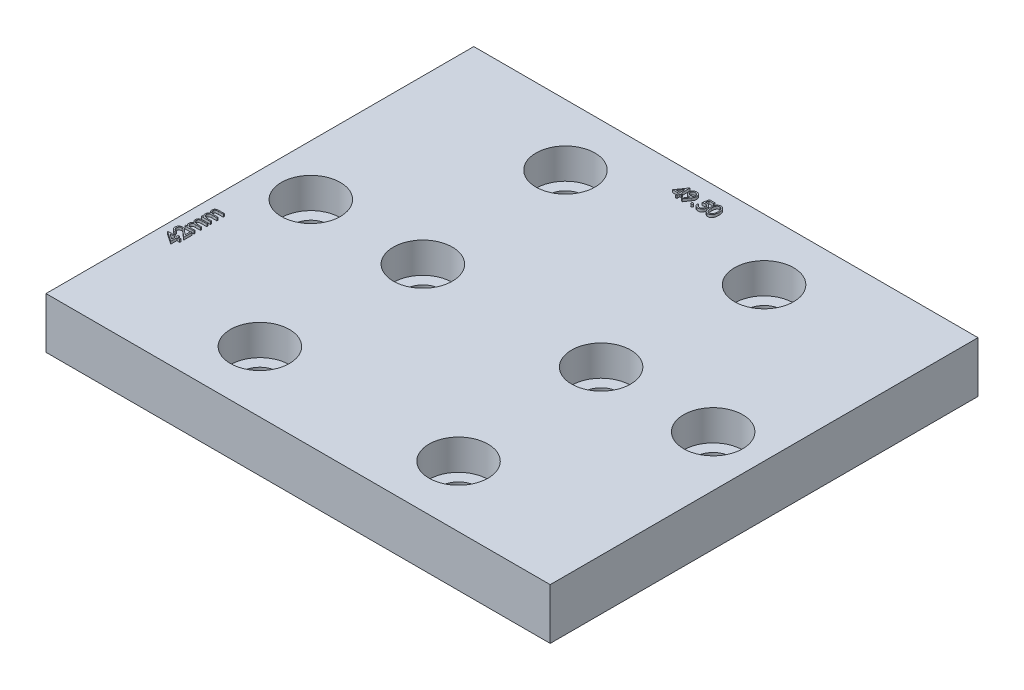
from build123d import *

# Parameters (mm, degrees)
SKETCH1_W               = 49.5
SKETCH1_H               = 42
BOSS_EXTRUDE1_DEPTH     = 5
SKETCH2_R               = 1.75
CUT_EXTRUDE1_DEPTH      = 33.841475302
BOSS_EXTRUDE2_DEPTH     = 0.25
BOSS_EXTRUDE3_DEPTH     = 0.25
SKETCH6_R               = 2.9
CUT_EXTRUDE2_DEPTH      = 33.841475441
CUT_EXTRUDE2_DEPTH_BACK = 3


with BuildPart() as part:
    # Sketch1 → Boss-Extrude1 (new body)
    with BuildSketch(Plane(origin=(0, 0, 0), x_dir=(1, 0, 0), z_dir=(0, 1, 0))):
        Rectangle(SKETCH1_W, SKETCH1_H)
    extrude(amount=BOSS_EXTRUDE1_DEPTH)

    # Sketch2 → Cut-Extrude1 (cut, through all)
    with BuildSketch(Plane(origin=(0, 5, 0), x_dir=(1, 0, 0), z_dir=(0, 1, 0))):
        with Locations(Location((-9.75, 15, 0), (0, 0, 270))):
            Circle(SKETCH2_R)
        with Locations(Location((9.75, 15, 0), (0, 0, 270))):
            Circle(SKETCH2_R)
        with Locations(Location((19.75, 0, 0), (0, 0, 270))):
            Circle(SKETCH2_R)
        with Locations(Location((-19.75, 0, 0), (0, 0, 270))):
            Circle(SKETCH2_R)
        with Locations(Location((-9.75, -15, 0), (0, 0, 270))):
            Circle(SKETCH2_R)
        with Locations(Location((9.75, -15, 0), (0, 0, 270))):
            Circle(SKETCH2_R)
        with Locations(Location((-8.75, 0, 0), (0, 0, 270))):
            Circle(SKETCH2_R)
        with Locations(Location((8.75, 0, 0), (0, 0, 270))):
            Circle(SKETCH2_R)
    extrude(amount=-CUT_EXTRUDE1_DEPTH, mode=Mode.SUBTRACT)

    # Sketch3 → Boss-Extrude2 (add)
    with BuildSketch(Plane(origin=(-31.590216695, 5, -10.723104051), x_dir=(0, 0, -1), z_dir=(0, 1, 0))):
        Polygon((-20.719932362, -7.772062893), (-20.697145903, -7.772062893), (-20.697145903, -8.637447508), (-20.552915134, -8.637447508), (-20.552915134, -8.765652636), (-20.697145903, -8.765652636), (-20.697145903, -9.054114175), (-20.80932539, -9.054114175), (-20.80932539, -8.765652636), (-21.402274108, -8.765652636), align=None)
        Polygon((-20.80932539, -8.637447508), (-20.80932539, -8.09507972), (-21.181671144, -8.637447508), align=None, mode=Mode.SUBTRACT)
        with BuildLine():
            Line((-20.280479237, -8.188729559), (-20.392658724, -8.188729559))
            add(Edge.make_bspline(
                [(-20.392658724, -8.188729559), (-20.391927598, -8.173847099), (-20.390491685, -8.144618344), (-20.383767296, -8.102002663), (-20.374145555, -8.061268807), (-20.360541464, -8.022743837), (-20.343646365, -7.986087121), (-20.323385641, -7.951444258), (-20.299387837, -7.918947405), (-20.272171146, -7.888897818), (-20.242610918, -7.861330828), (-20.21071594, -7.837525384), (-20.177199858, -7.81741193), (-20.142164359, -7.800597201), (-20.105214157, -7.787975828), (-20.066684565, -7.778610956), (-20.026406302, -7.772976547), (-19.998963437, -7.772370909), (-19.98500648, -7.772062893)],
                knots=[0, 0, 0, 0, 1.10065271, 2.161652631, 3.183658789, 4.190468796, 5.17591951, 6.163126047, 7.15150782, 8.156236427, 9.156009102, 10.134482811, 11.092018607, 12.041330605, 13.001268258, 13.972401359, 14.968799086, 16, 16, 16, 16], degree=3))
            add(Edge.make_bspline(
                [(-19.98500648, -7.772062893), (-19.971300025, -7.77238377), (-19.944367331, -7.773014282), (-19.905059468, -7.778428936), (-19.867639006, -7.786909504), (-19.832179089, -7.798807867), (-19.798962638, -7.814802305), (-19.767740122, -7.834015712), (-19.738139832, -7.85623708), (-19.711494552, -7.882399157), (-19.687027381, -7.91032858), (-19.665919433, -7.940145688), (-19.647843303, -7.970941862), (-19.632776275, -8.002951934), (-19.621684796, -8.036477301), (-19.613264008, -8.071029873), (-19.608504217, -8.106967306), (-19.607773709, -8.131291076), (-19.607402313, -8.143657444)],
                knots=[0, 0, 0, 0, 1.111607364, 2.184268762, 3.212621178, 4.221274766, 5.211760367, 6.196651075, 7.1921475, 8.207485113, 9.220403448, 10.201281604, 11.166441695, 12.114753415, 13.065576456, 14.026450734, 14.996634279, 16, 16, 16, 16], degree=3))
            add(Edge.make_bspline(
                [(-19.607402313, -8.143657444), (-19.608004687, -8.16106809), (-19.609198862, -8.19558385), (-19.61950447, -8.246371121), (-19.635426648, -8.295622928), (-19.654738444, -8.335258303), (-19.67424579, -8.367035765), (-19.691452859, -8.393434209), (-19.712042985, -8.4215865), (-19.735827776, -8.451776182), (-19.762448421, -8.4840956), (-19.792096517, -8.518558016), (-19.824998549, -8.554797411), (-19.848090757, -8.579549487), (-19.86005656, -8.592375393)],
                knots=[0, 0, 0, 0, 1.184203166, 2.347625244, 3.513805382, 4.700623107, 5.337941753, 6.051866363, 6.845199593, 7.711357327, 8.668078039, 9.695487809, 10.805859518, 12, 12, 12, 12], degree=3))
            Line((-19.86005656, -8.592375393), (-20.172806961, -8.925909047))
            Line((-20.172806961, -8.925909047), (-19.591376672, -8.925909047))
            Line((-19.591376672, -8.925909047), (-19.591376672, -9.054114175))
            Line((-19.591376672, -9.054114175), (-20.440735647, -9.054114175))
            Line((-20.440735647, -9.054114175), (-19.955960006, -8.53678645))
            add(Edge.make_bspline(
                [(-19.955960006, -8.53678645), (-19.944157189, -8.524465627), (-19.921486394, -8.500799846), (-19.889421188, -8.466248788), (-19.860621549, -8.434195381), (-19.834901052, -8.404700185), (-19.812817657, -8.377331768), (-19.793220431, -8.352976517), (-19.777518434, -8.330564213), (-19.760477222, -8.304585422), (-19.743972228, -8.272866738), (-19.729789244, -8.234104706), (-19.721141084, -8.194202116), (-19.720103642, -8.167237102), (-19.719581801, -8.15367347)],
                knots=[0, 0, 0, 0, 1.329631726, 2.553950428, 3.673215718, 4.687767853, 5.603093632, 6.413772471, 7.123043292, 7.734684054, 8.834405432, 9.900288307, 10.943827018, 12, 12, 12, 12], degree=3))
            add(Edge.make_bspline(
                [(-19.719581801, -8.15367347), (-19.719808851, -8.145144399), (-19.720256325, -8.128335238), (-19.724205503, -8.103690324), (-19.730173541, -8.079917176), (-19.738725418, -8.056942669), (-19.75001354, -8.034997794), (-19.763754033, -8.014055836), (-19.779607627, -7.993809777), (-19.797947366, -7.974826457), (-19.818094337, -7.957440312), (-19.839377998, -7.942038853), (-19.861895892, -7.929167742), (-19.885553079, -7.918616493), (-19.910283603, -7.910339571), (-19.936135298, -7.904604364), (-19.963036733, -7.901003477), (-19.981405838, -7.900516273), (-19.990765695, -7.900268021)],
                knots=[0, 0, 0, 0, 0.991446411, 1.95395049, 2.89581595, 3.838931463, 4.798493298, 5.75982156, 6.748411868, 7.785213223, 8.824556874, 9.840280684, 10.836137867, 11.835679398, 12.848801643, 13.863922112, 14.911575587, 16, 16, 16, 16], degree=3))
            add(Edge.make_bspline(
                [(-19.990765695, -7.900268021), (-20.000540992, -7.90052339), (-20.019738062, -7.901024891), (-20.047923431, -7.904532986), (-20.074811209, -7.910585072), (-20.100469031, -7.918862455), (-20.124940312, -7.929383366), (-20.148106042, -7.94248756), (-20.169914217, -7.958124522), (-20.190405832, -7.975853292), (-20.209285825, -7.995591721), (-20.225873995, -8.017595279), (-20.240368286, -8.041462213), (-20.25301444, -8.067128124), (-20.26328433, -8.094825903), (-20.271131883, -8.124457226), (-20.277341472, -8.155893434), (-20.279415943, -8.177602393), (-20.280479237, -8.188729559)],
                knots=[0, 0, 0, 0, 1.031018746, 2.02475058, 2.990194455, 3.934040569, 4.864654155, 5.795059489, 6.735614925, 7.690564532, 8.649604399, 9.611025574, 10.590972636, 11.591080095, 12.624614302, 13.701020113, 14.821632451, 16, 16, 16, 16], degree=3))
        make_face()
        with BuildLine():
            Line((-19.39906898, -8.140652636), (-19.286889493, -8.140652636))
            Line((-19.286889493, -8.140652636), (-19.286889493, -8.299406643))
            add(Edge.make_bspline(
                [(-19.286889493, -8.299406643), (-19.276788082, -8.285518213), (-19.257432811, -8.258906652), (-19.225695078, -8.223838693), (-19.193989323, -8.194078638), (-19.171155973, -8.178456184), (-19.160186769, -8.170951114)],
                knots=[0, 0, 0, 0, 1.134379233, 2.173579362, 3.122582517, 4, 4, 4, 4], degree=3))
            add(Edge.make_bspline(
                [(-19.160186769, -8.170951114), (-19.145235104, -8.163806341), (-19.115592996, -8.149641621), (-19.068657559, -8.135272493), (-19.020630891, -8.1264421), (-18.988199386, -8.125234467), (-18.971885487, -8.124626995)],
                knots=[0, 0, 0, 0, 1.014936303, 2.012140481, 3.000054389, 4, 4, 4, 4], degree=3))
            add(Edge.make_bspline(
                [(-18.971885487, -8.124626995), (-18.960852273, -8.125000313), (-18.939018138, -8.12573909), (-18.906666677, -8.130546245), (-18.875288602, -8.138855593), (-18.845069305, -8.150429637), (-18.816597634, -8.164446311), (-18.790494349, -8.180892635), (-18.767057132, -8.199355876), (-18.746297828, -8.220669781), (-18.727630319, -8.245432852), (-18.710459302, -8.274312941), (-18.694593155, -8.307958534), (-18.685799831, -8.332375156), (-18.681170342, -8.34522996)],
                knots=[0, 0, 0, 0, 1.009824226, 1.998387844, 2.986035974, 3.974953746, 4.955485308, 5.885931332, 6.793869504, 7.679848016, 8.601185859, 9.625726857, 10.749998409, 12, 12, 12, 12], degree=3))
            add(Edge.make_bspline(
                [(-18.681170342, -8.34522996), (-18.676273467, -8.33639981), (-18.666637104, -8.319023316), (-18.650456519, -8.294431079), (-18.633503734, -8.271428653), (-18.615634273, -8.249997788), (-18.596911206, -8.230244312), (-18.57724642, -8.212102919), (-18.556751855, -8.1954957), (-18.528254627, -8.176094571), (-18.491178696, -8.155487007), (-18.44443294, -8.137619705), (-18.395807879, -8.126578231), (-18.362801558, -8.125281705), (-18.346134285, -8.124626995)],
                knots=[0, 0, 0, 0, 0.86119277, 1.694706429, 2.50939023, 3.298075842, 4.073795165, 4.829715201, 5.57930267, 6.321991688, 7.768977793, 9.186738141, 10.579381044, 12, 12, 12, 12], degree=3))
            add(Edge.make_bspline(
                [(-18.346134285, -8.124626995), (-18.330819476, -8.125204574), (-18.30084691, -8.126334952), (-18.257212172, -8.135211193), (-18.21651867, -8.150453209), (-18.178848286, -8.171250937), (-18.144862638, -8.197386359), (-18.115321099, -8.228482373), (-18.090403112, -8.264319024), (-18.074125027, -8.298030448), (-18.063083861, -8.327793067), (-18.056276277, -8.353152457), (-18.0502621, -8.381063726), (-18.045268799, -8.411560248), (-18.041619316, -8.444749751), (-18.038915489, -8.480577921), (-18.037085462, -8.519072603), (-18.036956151, -8.545631711), (-18.036889493, -8.559322508)],
                knots=[0, 0, 0, 0, 1.209669288, 2.367440248, 3.500751976, 4.631527125, 5.755587489, 6.87532382, 8.007944318, 9.190864318, 9.82315674, 10.514484317, 11.263564316, 12.079023757, 12.955305781, 13.901327259, 14.918167583, 16, 16, 16, 16], degree=3))
            Line((-18.036889493, -8.559322508), (-18.036889493, -9.054114175))
            Line((-18.036889493, -9.054114175), (-18.14906898, -9.054114175))
            Line((-18.14906898, -9.054114175), (-18.14906898, -8.558821707))
            add(Edge.make_bspline(
                [(-18.14906898, -8.558821707), (-18.149096795, -8.547135788), (-18.149150252, -8.524677228), (-18.150112264, -8.49244421), (-18.151924876, -8.463062653), (-18.15404439, -8.436572622), (-18.156988607, -8.41291234), (-18.160790726, -8.392129334), (-18.164818469, -8.374060115), (-18.171509894, -8.354029384), (-18.18220557, -8.33193288), (-18.198497527, -8.308103032), (-18.219022565, -8.287359889), (-18.242722621, -8.269353347), (-18.269704208, -8.254712761), (-18.299441609, -8.244257043), (-18.331750199, -8.237784587), (-18.35411548, -8.237139581), (-18.365665535, -8.236806482)],
                knots=[0, 0, 0, 0, 1.253487763, 2.409012846, 3.458416907, 4.410876679, 5.259312806, 6.014470957, 6.676830364, 7.243083969, 8.276244668, 9.299465089, 10.325150304, 11.392391894, 12.482080715, 13.603491619, 14.762376348, 16, 16, 16, 16], degree=3))
            add(Edge.make_bspline(
                [(-18.365665535, -8.236806482), (-18.379833375, -8.237312253), (-18.407834415, -8.238311848), (-18.448707803, -8.248516802), (-18.487983166, -8.263902606), (-18.524488571, -8.286199912), (-18.558069925, -8.312917185), (-18.586962631, -8.344684898), (-18.610831269, -8.380624157), (-18.626993403, -8.413890837), (-18.637203868, -8.443772781), (-18.643945623, -8.469878985), (-18.649189692, -8.499550974), (-18.654107738, -8.532589363), (-18.657317641, -8.569221571), (-18.660234916, -8.609278143), (-18.66159951, -8.652879557), (-18.661790388, -8.683103374), (-18.661889493, -8.698795665)],
                knots=[0, 0, 0, 0, 1.090531906, 2.155305635, 3.229839962, 4.33261226, 5.44038871, 6.529323825, 7.629011124, 8.757537029, 9.370236727, 10.061839251, 10.834451254, 11.692844982, 12.636905849, 13.66920014, 14.789842145, 16, 16, 16, 16], degree=3))
            Line((-18.661889493, -8.698795665), (-18.661889493, -9.054114175))
            Line((-18.661889493, -9.054114175), (-18.77406898, -9.054114175))
            Line((-18.77406898, -9.054114175), (-18.77406898, -8.589620986))
            add(Edge.make_bspline(
                [(-18.77406898, -8.589620986), (-18.774097348, -8.576516229), (-18.774151926, -8.551303994), (-18.775107754, -8.51514911), (-18.776924404, -8.48226301), (-18.7790246, -8.452683916), (-18.782046092, -8.426465584), (-18.78547815, -8.403467456), (-18.789531225, -8.383747188), (-18.796241898, -8.362117408), (-18.806497066, -8.338288507), (-18.822992874, -8.312880999), (-18.843567009, -8.290642393), (-18.867699465, -8.271657126), (-18.894844352, -8.255963739), (-18.924838423, -8.244656685), (-18.957411606, -8.238076582), (-18.97986793, -8.237237833), (-18.991416737, -8.236806482)],
                knots=[0, 0, 0, 0, 1.320475261, 2.540461679, 3.643808994, 4.639130445, 5.527981419, 6.302341397, 6.981980563, 7.553956391, 8.582137848, 9.585246428, 10.591171744, 11.620968678, 12.668337649, 13.738356861, 14.836885341, 16, 16, 16, 16], degree=3))
            add(Edge.make_bspline(
                [(-18.991416737, -8.236806482), (-19.004993955, -8.237353075), (-19.032052869, -8.238442415), (-19.071803572, -8.248247513), (-19.110191317, -8.263606111), (-19.146603709, -8.28491319), (-19.180058762, -8.311305718), (-19.209347429, -8.342346752), (-19.233969759, -8.377649978), (-19.25030255, -8.410565877), (-19.26083772, -8.439699189), (-19.267836054, -8.464467385), (-19.273850206, -8.491967474), (-19.278319499, -8.522284299), (-19.282633933, -8.555220404), (-19.284716187, -8.590939865), (-19.286741744, -8.629412039), (-19.286839035, -8.655973662), (-19.286889493, -8.669749191)],
                knots=[0, 0, 0, 0, 1.098833095, 2.189935336, 3.297829714, 4.440610912, 5.596351641, 6.740013378, 7.886572111, 9.072425424, 9.705826452, 10.395263256, 11.156850408, 11.985370555, 12.878090359, 13.847760091, 14.883794034, 16, 16, 16, 16], degree=3))
            Line((-19.286889493, -8.669749191), (-19.286889493, -9.054114175))
            Line((-19.286889493, -9.054114175), (-19.39906898, -9.054114175))
            Line((-19.39906898, -9.054114175), (-19.39906898, -8.140652636))
        make_face()
        with BuildLine():
            Line((-17.780479237, -8.140652636), (-17.668299749, -8.140652636))
            Line((-17.668299749, -8.140652636), (-17.668299749, -8.299406643))
            add(Edge.make_bspline(
                [(-17.668299749, -8.299406643), (-17.658198339, -8.285518213), (-17.638843067, -8.258906652), (-17.607105334, -8.223838693), (-17.57539958, -8.194078638), (-17.552566229, -8.178456184), (-17.541597025, -8.170951114)],
                knots=[0, 0, 0, 0, 1.134379233, 2.173579362, 3.122582517, 4, 4, 4, 4], degree=3))
            add(Edge.make_bspline(
                [(-17.541597025, -8.170951114), (-17.52664536, -8.163806341), (-17.497003253, -8.149641621), (-17.450067815, -8.135272493), (-17.402041148, -8.1264421), (-17.369609643, -8.125234467), (-17.353295743, -8.124626995)],
                knots=[0, 0, 0, 0, 1.014936303, 2.012140481, 3.000054389, 4, 4, 4, 4], degree=3))
            add(Edge.make_bspline(
                [(-17.353295743, -8.124626995), (-17.34226253, -8.125000313), (-17.320428394, -8.12573909), (-17.288076934, -8.130546245), (-17.256698858, -8.138855593), (-17.226479562, -8.150429637), (-17.198007891, -8.164446311), (-17.171904606, -8.180892635), (-17.148467389, -8.199355876), (-17.127708085, -8.220669781), (-17.109040576, -8.245432852), (-17.091869559, -8.274312941), (-17.076003412, -8.307958534), (-17.067210087, -8.332375156), (-17.062580599, -8.34522996)],
                knots=[0, 0, 0, 0, 1.009824226, 1.998387844, 2.986035974, 3.974953746, 4.955485308, 5.885931332, 6.793869504, 7.679848016, 8.601185859, 9.625726857, 10.749998409, 12, 12, 12, 12], degree=3))
            add(Edge.make_bspline(
                [(-17.062580599, -8.34522996), (-17.057683723, -8.33639981), (-17.04804736, -8.319023316), (-17.031866775, -8.294431079), (-17.014913991, -8.271428653), (-16.997044529, -8.249997788), (-16.978321462, -8.230244312), (-16.958656676, -8.212102919), (-16.938162112, -8.1954957), (-16.909664883, -8.176094571), (-16.872588952, -8.155487007), (-16.825843197, -8.137619705), (-16.777218135, -8.126578231), (-16.744211815, -8.125281705), (-16.727544541, -8.124626995)],
                knots=[0, 0, 0, 0, 0.86119277, 1.694706429, 2.50939023, 3.298075842, 4.073795165, 4.829715201, 5.57930267, 6.321991688, 7.768977793, 9.186738141, 10.579381044, 12, 12, 12, 12], degree=3))
            add(Edge.make_bspline(
                [(-16.727544541, -8.124626995), (-16.712229733, -8.125204574), (-16.682257166, -8.126334952), (-16.638622429, -8.135211193), (-16.597928927, -8.150453209), (-16.560258542, -8.171250937), (-16.526272895, -8.197386359), (-16.496731356, -8.228482373), (-16.471813369, -8.264319024), (-16.455535283, -8.298030448), (-16.444494117, -8.327793067), (-16.437686534, -8.353152457), (-16.431672357, -8.381063726), (-16.426679055, -8.411560248), (-16.423029572, -8.444749751), (-16.420325745, -8.480577921), (-16.418495719, -8.519072603), (-16.418366407, -8.545631711), (-16.418299749, -8.559322508)],
                knots=[0, 0, 0, 0, 1.209669288, 2.367440248, 3.500751976, 4.631527125, 5.755587489, 6.87532382, 8.007944318, 9.190864318, 9.82315674, 10.514484317, 11.263564316, 12.079023757, 12.955305781, 13.901327259, 14.918167583, 16, 16, 16, 16], degree=3))
            Line((-16.418299749, -8.559322508), (-16.418299749, -9.054114175))
            Line((-16.418299749, -9.054114175), (-16.530479237, -9.054114175))
            Line((-16.530479237, -9.054114175), (-16.530479237, -8.558821707))
            add(Edge.make_bspline(
                [(-16.530479237, -8.558821707), (-16.530507052, -8.547135788), (-16.530560509, -8.524677228), (-16.53152252, -8.49244421), (-16.533335132, -8.463062653), (-16.535454646, -8.436572622), (-16.538398864, -8.41291234), (-16.542200982, -8.392129334), (-16.546228725, -8.374060115), (-16.55292015, -8.354029384), (-16.563615826, -8.33193288), (-16.579907783, -8.308103032), (-16.600432821, -8.287359889), (-16.624132877, -8.269353347), (-16.651114464, -8.254712761), (-16.680851865, -8.244257043), (-16.713160455, -8.237784587), (-16.735525737, -8.237139581), (-16.747075791, -8.236806482)],
                knots=[0, 0, 0, 0, 1.253487763, 2.409012846, 3.458416907, 4.410876679, 5.259312806, 6.014470957, 6.676830364, 7.243083969, 8.276244668, 9.299465089, 10.325150304, 11.392391894, 12.482080715, 13.603491619, 14.762376348, 16, 16, 16, 16], degree=3))
            add(Edge.make_bspline(
                [(-16.747075791, -8.236806482), (-16.761243632, -8.237312253), (-16.789244672, -8.238311848), (-16.830118059, -8.248516802), (-16.869393423, -8.263902606), (-16.905898827, -8.286199912), (-16.939480181, -8.312917185), (-16.968372887, -8.344684898), (-16.992241525, -8.380624157), (-17.008403659, -8.413890837), (-17.018614124, -8.443772781), (-17.02535588, -8.469878985), (-17.030599948, -8.499550974), (-17.035517994, -8.532589363), (-17.038727897, -8.569221571), (-17.041645173, -8.609278143), (-17.043009767, -8.652879557), (-17.043200645, -8.683103374), (-17.043299749, -8.698795665)],
                knots=[0, 0, 0, 0, 1.090531906, 2.155305635, 3.229839962, 4.33261226, 5.44038871, 6.529323825, 7.629011124, 8.757537029, 9.370236727, 10.061839251, 10.834451254, 11.692844982, 12.636905849, 13.66920014, 14.789842145, 16, 16, 16, 16], degree=3))
            Line((-17.043299749, -8.698795665), (-17.043299749, -9.054114175))
            Line((-17.043299749, -9.054114175), (-17.155479237, -9.054114175))
            Line((-17.155479237, -9.054114175), (-17.155479237, -8.589620986))
            add(Edge.make_bspline(
                [(-17.155479237, -8.589620986), (-17.155507605, -8.576516229), (-17.155562182, -8.551303994), (-17.15651801, -8.51514911), (-17.158334661, -8.48226301), (-17.160434856, -8.452683916), (-17.163456349, -8.426465584), (-17.166888407, -8.403467456), (-17.170941482, -8.383747188), (-17.177652155, -8.362117408), (-17.187907322, -8.338288507), (-17.20440313, -8.312880999), (-17.224977266, -8.290642393), (-17.249109721, -8.271657126), (-17.276254608, -8.255963739), (-17.30624868, -8.244656685), (-17.338821863, -8.238076582), (-17.361278186, -8.237237833), (-17.372826993, -8.236806482)],
                knots=[0, 0, 0, 0, 1.320475261, 2.540461679, 3.643808994, 4.639130445, 5.527981419, 6.302341397, 6.981980563, 7.553956391, 8.582137848, 9.585246428, 10.591171744, 11.620968678, 12.668337649, 13.738356861, 14.836885341, 16, 16, 16, 16], degree=3))
            add(Edge.make_bspline(
                [(-17.372826993, -8.236806482), (-17.386404211, -8.237353075), (-17.413463125, -8.238442415), (-17.453213829, -8.248247513), (-17.491601573, -8.263606111), (-17.528013965, -8.28491319), (-17.561469018, -8.311305718), (-17.590757685, -8.342346752), (-17.615380016, -8.377649978), (-17.631712807, -8.410565877), (-17.642247976, -8.439699189), (-17.64924631, -8.464467385), (-17.655260462, -8.491967474), (-17.659729756, -8.522284299), (-17.66404419, -8.555220404), (-17.666126443, -8.590939865), (-17.668152001, -8.629412039), (-17.668249292, -8.655973662), (-17.668299749, -8.669749191)],
                knots=[0, 0, 0, 0, 1.098833095, 2.189935336, 3.297829714, 4.440610912, 5.596351641, 6.740013378, 7.886572111, 9.072425424, 9.705826452, 10.395263256, 11.156850408, 11.985370555, 12.878090359, 13.847760091, 14.883794034, 16, 16, 16, 16], degree=3))
            Line((-17.668299749, -8.669749191), (-17.668299749, -9.054114175))
            Line((-17.668299749, -9.054114175), (-17.780479237, -9.054114175))
            Line((-17.780479237, -9.054114175), (-17.780479237, -8.140652636))
        make_face()
    extrude(amount=BOSS_EXTRUDE2_DEPTH)

    # Sketch5 → Boss-Extrude3 (add)
    with BuildSketch(Plane(origin=(-2.612932279, 5, -18.047462483), x_dir=(1, 0, 0), z_dir=(0, 1, 0))):
        Polygon((0.73041867, 1.282051282), (0.753205128, 1.282051282), (0.753205128, 0.416666667), (0.897435897, 0.416666667), (0.897435897, 0.288461538), (0.753205128, 0.288461538), (0.753205128, 0), (0.641025641, 0), (0.641025641, 0.288461538), (0.048076923, 0.288461538), align=None)
        Polygon((0.641025641, 0.416666667), (0.641025641, 0.959034455), (0.268679888, 0.416666667), align=None, mode=Mode.SUBTRACT)
        with BuildLine():
            Line((1.282051282, -0.032051282), (1.192407853, 0.030298478))
            Line((1.192407853, 0.030298478), (1.539963942, 0.538361378))
            add(Edge.make_bspline(
                [(1.539963942, 0.538361378), (1.51778868, 0.53564957), (1.474124351, 0.530309868), (1.430146815, 0.52932892), (1.408503606, 0.528846154)],
                knots=[0, 0, 0, 0, 1.015715272, 2, 2, 2, 2], degree=3))
            add(Edge.make_bspline(
                [(1.408503606, 0.528846154), (1.395381446, 0.529182253), (1.369623793, 0.529841985), (1.331755346, 0.535071202), (1.295367646, 0.543124819), (1.260557162, 0.555142232), (1.227193053, 0.570077306), (1.195348155, 0.588597669), (1.165065337, 0.61038563), (1.136669833, 0.635325984), (1.110844212, 0.662711003), (1.087835892, 0.691695161), (1.068714059, 0.72261515), (1.052829564, 0.754840229), (1.040782974, 0.788833568), (1.032010639, 0.824208354), (1.026609798, 0.861212512), (1.025967264, 0.886400059), (1.025641026, 0.899188702)],
                knots=[0, 0, 0, 0, 1.060718605, 2.082097864, 3.085795603, 4.069760067, 5.054557537, 6.03741023, 7.043284206, 8.066802108, 9.088538119, 10.083643548, 11.053783639, 12.022749082, 12.983451788, 13.964007469, 14.966251758, 16, 16, 16, 16], degree=3))
            add(Edge.make_bspline(
                [(1.025641026, 0.899188702), (1.026260467, 0.916677506), (1.027476304, 0.951004482), (1.037261488, 1.0011594), (1.053354467, 1.048583165), (1.075793173, 1.093151092), (1.104055573, 1.13422207), (1.138022927, 1.171225144), (1.177488628, 1.203634021), (1.221553635, 1.23149262), (1.269179714, 1.253897976), (1.319061378, 1.270412012), (1.37081642, 1.280125851), (1.405876303, 1.281406515), (1.423527644, 1.282051282)],
                knots=[0, 0, 0, 0, 1.022988612, 2.007919123, 2.978103895, 3.94594894, 4.918897164, 5.887013414, 6.875921846, 7.89917871, 8.930658928, 9.948724884, 10.967259574, 12, 12, 12, 12], degree=3))
            add(Edge.make_bspline(
                [(1.423527644, 1.282051282), (1.440844937, 1.281397652), (1.475062275, 1.280106142), (1.525379777, 1.270647581), (1.573572998, 1.254705913), (1.619374779, 1.232675711), (1.661781712, 1.205061101), (1.69991593, 1.172155914), (1.732907194, 1.133939655), (1.760701437, 1.091336622), (1.783012166, 1.045562701), (1.79910941, 0.997782728), (1.809018566, 0.948340328), (1.810267255, 0.914842301), (1.810897436, 0.897936699)],
                knots=[0, 0, 0, 0, 1.026385292, 2.028040595, 3.023318987, 4.028184125, 5.03290303, 6.015178782, 7.004435299, 8.016004309, 9.023023918, 10.015172535, 10.998308025, 12, 12, 12, 12], degree=3))
            add(Edge.make_bspline(
                [(1.810897436, 0.897936699), (1.810476576, 0.884813925), (1.809622966, 0.85819766), (1.803645713, 0.817758252), (1.793495647, 0.77652567), (1.781977183, 0.7416251), (1.770858552, 0.712800654), (1.760393862, 0.690032232), (1.748782379, 0.666067496), (1.735239962, 0.641157732), (1.720681999, 0.614985398), (1.704232258, 0.587813), (1.686265982, 0.559604073), (1.673469653, 0.540587256), (1.666917067, 0.530849359)],
                knots=[0, 0, 0, 0, 1.179839688, 2.393009684, 3.667231171, 4.993948276, 5.694988576, 6.444077775, 7.246288328, 8.089075292, 8.993003841, 9.939041771, 10.944649915, 12, 12, 12, 12], degree=3))
            Line((1.666917067, 0.530849359), (1.282051282, -0.032051282))
        make_face()
        with BuildLine():
            add(Edge.make_bspline(
                [(1.429286859, 0.657051282), (1.439227578, 0.657322848), (1.458578779, 0.657851494), (1.486927815, 0.66106908), (1.513686459, 0.666774075), (1.538926191, 0.674959687), (1.562900084, 0.684837068), (1.585227344, 0.697412778), (1.605926657, 0.712418719), (1.625136631, 0.729279439), (1.642195202, 0.74801179), (1.657389142, 0.767617899), (1.67030363, 0.788183831), (1.6805048, 0.809967139), (1.688892149, 0.832437571), (1.694684296, 0.855956984), (1.697892986, 0.880402841), (1.698439978, 0.897009505), (1.698717949, 0.905448718)],
                knots=[0, 0, 0, 0, 1.163407946, 2.26475976, 3.333800367, 4.359385343, 5.366239384, 6.363380779, 7.350133999, 8.353570782, 9.349036268, 10.310270964, 11.253520213, 12.184142, 13.120487599, 14.056272588, 15.012232024, 16, 16, 16, 16], degree=3))
            add(Edge.make_bspline(
                [(1.698717949, 0.905448718), (1.698478781, 0.913891456), (1.698007472, 0.930528906), (1.694226294, 0.955010955), (1.687574428, 0.978472834), (1.678649255, 1.001042988), (1.666892027, 1.022535978), (1.65278364, 1.043221646), (1.63602205, 1.062968835), (1.61673542, 1.081313115), (1.595937365, 1.098223079), (1.573772901, 1.113146677), (1.550424716, 1.125654247), (1.526035256, 1.135975308), (1.500553702, 1.144029514), (1.473995135, 1.14982143), (1.446225348, 1.153025628), (1.427374888, 1.153569161), (1.417768429, 1.153846154)],
                knots=[0, 0, 0, 0, 0.972161553, 1.915763587, 2.844109794, 3.775983486, 4.705125789, 5.659731448, 6.655561913, 7.682237399, 8.721216875, 9.739758359, 10.754845918, 11.767244016, 12.7857855, 13.828538656, 14.893392813, 16, 16, 16, 16], degree=3))
            add(Edge.make_bspline(
                [(1.417768429, 1.153846154), (1.408245518, 1.153568714), (1.389561643, 1.153024379), (1.362038729, 1.14982752), (1.33565974, 1.143990562), (1.310252019, 1.135979039), (1.285863283, 1.125653477), (1.2625162, 1.113146022), (1.240346551, 1.098226514), (1.219568436, 1.081299809), (1.20024775, 1.063054222), (1.183774347, 1.04313514), (1.169633671, 1.022546738), (1.157892598, 1.001040128), (1.148963128, 0.978473598), (1.142312413, 0.955010749), (1.138530925, 0.930528959), (1.138059659, 0.913891474), (1.137820513, 0.905448718)],
                knots=[0, 0, 0, 0, 1.099389452, 2.15699305, 3.192601482, 4.213358962, 5.227959689, 6.245255729, 7.266013209, 8.307253147, 9.336162325, 10.327954924, 11.284637477, 12.215801273, 13.149702402, 14.080068371, 15.025723358, 16, 16, 16, 16], degree=3))
            add(Edge.make_bspline(
                [(1.137820513, 0.905448718), (1.138036915, 0.897002933), (1.1384637, 0.880346298), (1.142580767, 0.855872587), (1.149465867, 0.832412517), (1.158687078, 0.809737979), (1.170830503, 0.788069458), (1.185731878, 0.767509686), (1.203198144, 0.747825597), (1.222995818, 0.729323021), (1.244663019, 0.712340101), (1.267804714, 0.697507822), (1.292022513, 0.684981949), (1.317401666, 0.674931455), (1.343754095, 0.666855861), (1.371316642, 0.661079595), (1.399998155, 0.657882356), (1.419430292, 0.657330965), (1.429286859, 0.657051282)],
                knots=[0, 0, 0, 0, 0.952633368, 1.87876736, 2.791047057, 3.707742249, 4.635551637, 5.587206343, 6.568248508, 7.601284464, 8.641511608, 9.671105535, 10.699146789, 11.713763218, 12.747829548, 13.806491675, 14.887386225, 16, 16, 16, 16], degree=3))
        make_face(mode=Mode.SUBTRACT)
        with BuildLine():
            add(Edge.make_bspline(
                [(2.171474359, 0.192307692), (2.178435149, 0.191894061), (2.192080964, 0.191083186), (2.211809224, 0.185520088), (2.22966446, 0.175641995), (2.245568833, 0.162476717), (2.258678289, 0.146513981), (2.268908415, 0.128801156), (2.274423052, 0.10890773), (2.275228021, 0.095182846), (2.275641026, 0.088141026)],
                knots=[0, 0, 0, 0, 1.020151414, 1.999887582, 2.974338812, 3.990962822, 5.007586832, 5.987933904, 6.967670073, 8, 8, 8, 8], degree=3))
            add(Edge.make_bspline(
                [(2.275641026, 0.088141026), (2.275214025, 0.081268408), (2.274371987, 0.067715707), (2.268921056, 0.047972327), (2.258600323, 0.030248433), (2.245659255, 0.014069098), (2.229660528, 0.000875929), (2.211767012, -0.008918122), (2.192127277, -0.014879544), (2.178442875, -0.015638935), (2.171474359, -0.016025641)],
                knots=[0, 0, 0, 0, 1.009421747, 1.99056486, 2.972319754, 3.999869655, 5.017953583, 5.993804169, 6.978383603, 8, 8, 8, 8], degree=3))
            add(Edge.make_bspline(
                [(2.171474359, -0.016025641), (2.164500821, -0.015652928), (2.150886649, -0.014925294), (2.131320222, -0.00879572), (2.113317734, 0.000784087), (2.097322122, 0.014093698), (2.084272668, 0.030165177), (2.07440646, 0.04809439), (2.068481407, 0.06765919), (2.067702167, 0.081257276), (2.067307692, 0.088141026)],
                knots=[0, 0, 0, 0, 1.022052826, 1.995314843, 2.982371812, 4.00089066, 5.028879526, 6.005146991, 6.990147033, 8, 8, 8, 8], degree=3))
            add(Edge.make_bspline(
                [(2.067307692, 0.088141026), (2.067687013, 0.095194376), (2.068427591, 0.108965176), (2.074418899, 0.128679142), (2.084196117, 0.146596442), (2.09741233, 0.162452364), (2.113313864, 0.175733543), (2.131276794, 0.185399541), (2.150933773, 0.191128259), (2.164508751, 0.19190773), (2.171474359, 0.192307692)],
                knots=[0, 0, 0, 0, 1.032775665, 2.016367738, 2.991239715, 4.008302682, 5.025365648, 6.011011707, 6.979408107, 8, 8, 8, 8], degree=3))
        make_face()
        with BuildLine():
            Line((3.221153846, 1.25), (3.221153846, 1.121794872))
            Line((3.221153846, 1.121794872), (2.796223958, 1.121794872))
            Line((2.796223958, 1.121794872), (2.728615785, 0.79301883))
            add(Edge.make_bspline(
                [(2.728615785, 0.79301883), (2.741850026, 0.796672499), (2.767489275, 0.803750903), (2.805332082, 0.811610107), (2.841257869, 0.816347766), (2.864570501, 0.816994662), (2.875851362, 0.817307692)],
                knots=[0, 0, 0, 0, 1.100273476, 2.13160584, 3.095893838, 4, 4, 4, 4], degree=3))
            add(Edge.make_bspline(
                [(2.875851362, 0.817307692), (2.889809841, 0.817005572), (2.917255697, 0.816411529), (2.957412464, 0.810707297), (2.99574564, 0.801728756), (3.032175058, 0.789185713), (3.066768111, 0.773146522), (3.099206526, 0.753110829), (3.12997721, 0.729706068), (3.158528136, 0.702797135), (3.184429675, 0.673182272), (3.207203242, 0.641340176), (3.226547025, 0.607580296), (3.242104437, 0.571580079), (3.254527414, 0.533737524), (3.262795983, 0.493654459), (3.268301951, 0.451708702), (3.268917089, 0.423028498), (3.269230769, 0.408403446)],
                knots=[0, 0, 0, 0, 1.052922333, 2.070308379, 3.05430497, 4.020497103, 4.973039431, 5.925935799, 6.892292201, 7.88610001, 8.88166317, 9.857072816, 10.836096531, 11.812156883, 12.81219415, 13.836441305, 14.89672472, 16, 16, 16, 16], degree=3))
            add(Edge.make_bspline(
                [(3.269230769, 0.408403446), (3.268993242, 0.398216938), (3.268521399, 0.377981586), (3.266121903, 0.347930085), (3.261502004, 0.318514788), (3.255299246, 0.289731791), (3.247248382, 0.261635586), (3.237502292, 0.234145755), (3.225575139, 0.207433395), (3.212492505, 0.181245754), (3.19776162, 0.156174859), (3.181412153, 0.132728792), (3.164138763, 0.110555835), (3.145552554, 0.089893787), (3.12548077, 0.070878424), (3.104166496, 0.053396894), (3.081779811, 0.037153562), (3.057974367, 0.022807778), (3.033280623, 0.009606722), (3.007341974, -0.001223112), (2.980748867, -0.010905444), (2.953118554, -0.018623132), (2.924513621, -0.024670473), (2.894886916, -0.02877783), (2.864393819, -0.031769415), (2.843724172, -0.031956686), (2.833283253, -0.032051282)],
                knots=[0, 0, 0, 0, 1.056347294, 2.098418968, 3.122841568, 4.141288669, 5.149314143, 6.15115421, 7.162517403, 8.180376062, 9.185164535, 10.17417709, 11.141909838, 12.097768115, 13.052685741, 14.0056014, 14.954263652, 15.917497458, 16.885230207, 17.854509472, 18.828990115, 19.81800267, 20.826176721, 21.857883937, 22.917946725, 24, 24, 24, 24], degree=3))
            add(Edge.make_bspline(
                [(2.833283253, -0.032051282), (2.820828189, -0.031804554), (2.796324321, -0.031319146), (2.760424118, -0.026241116), (2.725883187, -0.018968289), (2.69297958, -0.008026764), (2.661418414, 0.005682984), (2.631624586, 0.023010189), (2.602836809, 0.042645583), (2.576225368, 0.065817137), (2.551526756, 0.091144167), (2.529417288, 0.118629039), (2.509726725, 0.147818125), (2.492770387, 0.17885318), (2.478306808, 0.211652655), (2.466944312, 0.246339441), (2.457773471, 0.2827323), (2.453893678, 0.307787125), (2.451923077, 0.320512821)],
                knots=[0, 0, 0, 0, 1.0467383, 2.05933395, 3.04377827, 4.011590433, 4.970194871, 5.932262533, 6.905835911, 7.896367577, 8.894135286, 9.877477877, 10.858688626, 11.851381753, 12.8477658, 13.868841284, 14.917554742, 16, 16, 16, 16], degree=3))
            Line((2.451923077, 0.320512821), (2.564102564, 0.320512821))
            add(Edge.make_bspline(
                [(2.564102564, 0.320512821), (2.566862763, 0.308592659), (2.572168019, 0.285681446), (2.583812929, 0.253491682), (2.598050742, 0.224806245), (2.614980866, 0.199245679), (2.635177306, 0.176956752), (2.65822353, 0.157093515), (2.684062003, 0.139173826), (2.712773871, 0.124237124), (2.743064256, 0.111498283), (2.774766831, 0.103015535), (2.807018384, 0.09705093), (2.828832087, 0.096453873), (2.83979367, 0.096153846)],
                knots=[0, 0, 0, 0, 1.136247022, 2.183929868, 3.172523383, 4.106158343, 5.02341133, 5.958108904, 6.928429099, 7.938127109, 8.96079061, 9.975095812, 10.982467395, 12, 12, 12, 12], degree=3))
            add(Edge.make_bspline(
                [(2.83979367, 0.096153846), (2.850493114, 0.096446981), (2.871560408, 0.097024166), (2.902564475, 0.101466671), (2.932497644, 0.10830866), (2.961064557, 0.118547894), (2.988765107, 0.130992437), (3.014898596, 0.146962106), (3.040221053, 0.165340685), (3.063945386, 0.186396624), (3.085673761, 0.209600086), (3.104872375, 0.234413441), (3.12086413, 0.260883743), (3.134340598, 0.288552726), (3.144573919, 0.31772364), (3.151874269, 0.348259774), (3.156161076, 0.380236552), (3.156750783, 0.40204702), (3.157051282, 0.413161058)],
                knots=[0, 0, 0, 0, 1.027316725, 2.022795036, 3.002884548, 3.971462791, 4.93288096, 5.914575861, 6.907176829, 7.935150275, 8.956128384, 9.956726525, 10.942570165, 11.921478529, 12.907843606, 13.90538589, 14.932640048, 16, 16, 16, 16], degree=3))
            add(Edge.make_bspline(
                [(3.157051282, 0.413161058), (3.156816111, 0.423188112), (3.156355797, 0.442814644), (3.152594879, 0.471528646), (3.146053103, 0.49869759), (3.136973146, 0.524452673), (3.12544475, 0.548818188), (3.111356781, 0.571819281), (3.094444854, 0.593152793), (3.075126322, 0.612828705), (3.053962736, 0.630987589), (3.030589971, 0.64646762), (3.00549714, 0.659490448), (2.978986568, 0.670729018), (2.950427676, 0.678800713), (2.920386022, 0.684860672), (2.888537197, 0.688366159), (2.866761952, 0.688852548), (2.85556891, 0.689102564)],
                knots=[0, 0, 0, 0, 1.045622112, 2.046656509, 3.013763289, 3.955457236, 4.890082067, 5.820317437, 6.762574623, 7.722996705, 8.69280354, 9.665887285, 10.63943826, 11.638615906, 12.663482002, 13.728887084, 14.832589034, 16, 16, 16, 16], degree=3))
            add(Edge.make_bspline(
                [(2.85556891, 0.689102564), (2.845880007, 0.68889521), (2.82587488, 0.688467077), (2.795188156, 0.685314756), (2.762941112, 0.680229294), (2.729257364, 0.673234206), (2.694035754, 0.66408025), (2.657350611, 0.653110785), (2.619124801, 0.639995786), (2.593368471, 0.630091424), (2.580128205, 0.625)],
                knots=[0, 0, 0, 0, 0.817624296, 1.688186739, 2.600797293, 3.572016777, 4.590301741, 5.671205678, 6.80286297, 8, 8, 8, 8], degree=3))
            Line((2.580128205, 0.625), (2.708333333, 1.25))
            Line((2.708333333, 1.25), (3.221153846, 1.25))
        make_face()
        with BuildLine():
            add(Edge.make_bspline(
                [(3.397435897, 0.624499199), (3.397553047, 0.64453398), (3.397780611, 0.683451832), (3.40031219, 0.740160632), (3.404517669, 0.793360736), (3.410281017, 0.843054688), (3.417294581, 0.889255318), (3.426657255, 0.93183916), (3.437304684, 0.971003305), (3.449644844, 1.006875465), (3.463569054, 1.03993893), (3.478724147, 1.070805074), (3.495711574, 1.099427192), (3.513560471, 1.126262118), (3.532993354, 1.15087058), (3.553457208, 1.173600102), (3.575750735, 1.19392537), (3.599116095, 1.212441907), (3.623764832, 1.228673861), (3.648994356, 1.242971268), (3.674978322, 1.255185506), (3.701787673, 1.264789233), (3.729181444, 1.272721678), (3.757255396, 1.278146303), (3.786055884, 1.281559484), (3.805495682, 1.281885794), (3.815354567, 1.282051282)],
                knots=[0, 0, 0, 0, 1.646270934, 3.197905019, 4.663502075, 6.030701355, 7.308322542, 8.50163776, 9.611534131, 10.641858119, 11.616356847, 12.558055219, 13.465016945, 14.349605745, 15.204443733, 16.039544428, 16.859896111, 17.680448484, 18.487036065, 19.28249412, 20.06191084, 20.843045899, 21.620316918, 22.403196591, 23.190181807, 24, 24, 24, 24], degree=3))
            add(Edge.make_bspline(
                [(3.815354567, 1.282051282), (3.82529581, 1.281877062), (3.845065813, 1.281530594), (3.874294518, 1.278200615), (3.902847976, 1.272675214), (3.930604454, 1.264846294), (3.957791949, 1.255133552), (3.984197809, 1.242959582), (4.009986053, 1.228788558), (4.03474687, 1.212137173), (4.058752089, 1.193572075), (4.081412076, 1.172585407), (4.102728892, 1.149389079), (4.122970073, 1.12423127), (4.141561358, 1.096629454), (4.159266155, 1.067063701), (4.175113311, 1.035016963), (4.190375695, 1.001023939), (4.203549618, 0.964144061), (4.21543042, 0.924585218), (4.225030052, 0.881880151), (4.233026221, 0.836252921), (4.239220826, 0.787535962), (4.243732484, 0.735833707), (4.246115729, 0.681112139), (4.246564551, 0.643698621), (4.246794872, 0.624499199)],
                knots=[0, 0, 0, 0, 0.810914788, 1.612654377, 2.396697861, 3.181598691, 3.963628158, 4.749916497, 5.551656086, 6.361998678, 7.18212741, 8.025565596, 8.878627764, 9.750805457, 10.657531673, 11.591944965, 12.560506719, 13.57287815, 14.630710178, 15.753379473, 16.941251878, 18.199788006, 19.531962791, 20.947069417, 22.433333509, 24, 24, 24, 24], degree=3))
            add(Edge.make_bspline(
                [(4.246794872, 0.624499199), (4.246562163, 0.605383517), (4.246108739, 0.568137392), (4.243759201, 0.513662043), (4.239131119, 0.462234171), (4.233341837, 0.413730434), (4.225323636, 0.368352713), (4.215464648, 0.325943982), (4.204518104, 0.286321099), (4.191005678, 0.249808666), (4.176216139, 0.215897336), (4.160124997, 0.184230498), (4.142885773, 0.15452825), (4.124104079, 0.127028341), (4.104085003, 0.101535963), (4.082400078, 0.078501098), (4.059660583, 0.057368715), (4.035584721, 0.038564563), (4.010437738, 0.022105704), (3.984738068, 0.007386471), (3.958029716, -0.004482348), (3.930917948, -0.014673434), (3.90301496, -0.02245931), (3.874355534, -0.02784283), (3.84508545, -0.03161849), (3.825299177, -0.031906518), (3.815354567, -0.032051282)],
                knots=[0, 0, 0, 0, 1.561518951, 3.042555995, 4.452378317, 5.7783523, 7.031515105, 8.214008947, 9.334062868, 10.386615937, 11.391082383, 12.354592575, 13.286541444, 14.194233754, 15.072674879, 15.931287219, 16.775624067, 17.606195743, 18.42308326, 19.229000347, 20.022332153, 20.807536673, 21.593273796, 22.3848459, 23.188221202, 24, 24, 24, 24], degree=3))
            add(Edge.make_bspline(
                [(3.815354567, -0.032051282), (3.805495955, -0.031884727), (3.786056696, -0.031556312), (3.757252259, -0.02815855), (3.729294243, -0.022695871), (3.702044688, -0.015047083), (3.67536379, -0.005684642), (3.649615116, 0.006513102), (3.624512372, 0.020560984), (3.60012253, 0.036559349), (3.576903902, 0.054888521), (3.554725828, 0.075161482), (3.534145464, 0.097884129), (3.51499043, 0.122697672), (3.496785399, 0.14937383), (3.480039194, 0.178276821), (3.464549603, 0.209292039), (3.450391214, 0.242619864), (3.437838119, 0.278746624), (3.426749652, 0.318085616), (3.417994596, 0.360984058), (3.410500683, 0.407097403), (3.404456261, 0.456623807), (3.400329716, 0.509590156), (3.397779246, 0.565963445), (3.397552436, 0.604631222), (3.397435897, 0.624499199)],
                knots=[0, 0, 0, 0, 0.810891512, 1.598919785, 2.382837074, 3.152667961, 3.926044502, 4.706494248, 5.493654104, 6.291793342, 7.103789334, 7.925228297, 8.761435821, 9.622817696, 10.50288917, 11.416980706, 12.369136599, 13.353924996, 14.394355917, 15.514179734, 16.714354668, 17.994756427, 19.357759367, 20.818452758, 22.365282078, 24, 24, 24, 24], degree=3))
        make_face()
        with BuildLine():
            add(Edge.make_bspline(
                [(3.509615385, 0.625), (3.509658044, 0.608304036), (3.509740838, 0.575900449), (3.511903767, 0.52881357), (3.514850279, 0.484895595), (3.518650742, 0.444090761), (3.524294652, 0.406537185), (3.530618505, 0.371976584), (3.538314251, 0.340591856), (3.547419615, 0.312167638), (3.557790721, 0.286221542), (3.569114243, 0.262078251), (3.581278787, 0.23945256), (3.59489277, 0.218547699), (3.609719578, 0.199295498), (3.625424313, 0.181355201), (3.642593093, 0.165356279), (3.66634443, 0.146168116), (3.697700314, 0.126339854), (3.737207619, 0.109073394), (3.777803495, 0.098222516), (3.805357512, 0.096842603), (3.819110577, 0.096153846)],
                knots=[0, 0, 0, 0, 1.459021318, 2.831673884, 4.118529203, 5.306027144, 6.411944654, 7.436330062, 8.375795394, 9.233974572, 10.042671642, 10.816086306, 11.563610507, 12.285937304, 12.993564865, 13.685989202, 14.367179055, 15.041617293, 16.353048772, 17.594441528, 18.799311195, 20, 20, 20, 20], degree=3))
            add(Edge.make_bspline(
                [(3.819110577, 0.096153846), (3.832952603, 0.096724482), (3.860608075, 0.097864576), (3.901013002, 0.108864125), (3.940238098, 0.125460389), (3.970978077, 0.145084498), (3.9943647, 0.163773187), (4.011120768, 0.17970699), (4.026500071, 0.197548371), (4.041086526, 0.21679812), (4.054464767, 0.237824007), (4.066630174, 0.260524927), (4.077731369, 0.284963919), (4.084056028, 0.30202454), (4.087289663, 0.310747196)],
                knots=[0, 0, 0, 0, 1.353760809, 2.704726607, 4.075137775, 5.516104923, 6.260822281, 7.007110065, 7.778089737, 8.566572457, 9.372053459, 10.217411131, 11.088608312, 12, 12, 12, 12], degree=3))
            add(Edge.make_bspline(
                [(4.087289663, 0.310747196), (4.091058152, 0.321900674), (4.0987098, 0.344547018), (4.108571148, 0.379676894), (4.116337362, 0.416535024), (4.123324278, 0.454901137), (4.128093227, 0.495058173), (4.131931731, 0.536881882), (4.134192691, 0.580403797), (4.134472959, 0.609973437), (4.134615385, 0.625)],
                knots=[0, 0, 0, 0, 0.884706709, 1.796334032, 2.740027952, 3.714592787, 4.726048262, 5.777819803, 6.87074269, 8, 8, 8, 8], degree=3))
            add(Edge.make_bspline(
                [(4.134615385, 0.625), (4.134418888, 0.640024133), (4.1340345, 0.669414549), (4.132565219, 0.712456756), (4.128771085, 0.7533381), (4.124557114, 0.792234697), (4.118343821, 0.828931234), (4.111644604, 0.863734914), (4.102644171, 0.896214566), (4.093029966, 0.926878702), (4.082026253, 0.955378936), (4.069913491, 0.981848145), (4.056977148, 1.006414118), (4.042926348, 1.029009455), (4.02792789, 1.049735363), (4.011585908, 1.06817629), (3.994548632, 1.084903778), (3.970685351, 1.103997553), (3.939444534, 1.123466016), (3.900571088, 1.141382358), (3.860117287, 1.151671034), (3.832769624, 1.153121637), (3.819110577, 1.153846154)],
                knots=[0, 0, 0, 0, 1.31362396, 2.569729283, 3.763502607, 4.902122613, 5.988968491, 7.01645872, 7.998833611, 8.933434873, 9.825090667, 10.667526885, 11.477055099, 12.250526234, 12.991942729, 13.710640831, 14.402115721, 15.076753259, 16.378508321, 17.609869233, 18.806226677, 20, 20, 20, 20], degree=3))
            add(Edge.make_bspline(
                [(3.819110577, 1.153846154), (3.805285365, 1.153120637), (3.777609756, 1.151668282), (3.736735487, 1.141420692), (3.697555361, 1.123558918), (3.666397156, 1.103933071), (3.642517232, 1.085240817), (3.625701985, 1.069031369), (3.609935494, 1.051300564), (3.595411316, 1.031871308), (3.581808, 1.01099082), (3.569314782, 0.988494833), (3.558058592, 0.964269345), (3.547671258, 0.938334904), (3.53853812, 0.909913138), (3.531004561, 0.878567069), (3.524044899, 0.844116394), (3.519118018, 0.806359426), (3.514738105, 0.765544372), (3.511923338, 0.721516758), (3.509733603, 0.674350908), (3.50965558, 0.64177978), (3.509615385, 0.625)],
                knots=[0, 0, 0, 0, 1.207732386, 2.417664972, 3.655092373, 4.956220595, 5.625982001, 6.301752483, 6.994047911, 7.697131622, 8.419323945, 9.170223765, 9.943494443, 10.752040957, 11.610060368, 12.549350801, 13.567764191, 14.679664412, 15.874934091, 17.154273443, 18.533957287, 20, 20, 20, 20], degree=3))
        make_face(mode=Mode.SUBTRACT)
    extrude(amount=BOSS_EXTRUDE3_DEPTH)

    # Sketch6 → Cut-Extrude2 (cut, two sides)
    with BuildSketch(Plane(origin=(0, 5, 0), x_dir=(1, 0, 0), z_dir=(0, 1, 0))) as cut_extrude2_sk:
        with Locations(Location((-9.75, 15, 0), (0, 0, 270))):
            Circle(SKETCH6_R)
        with Locations(Location((9.75, 15, 0), (0, 0, 270))):
            Circle(SKETCH6_R)
        with Locations(Location((-8.75, 0, 0), (0, 0, 270))):
            Circle(SKETCH6_R)
        with Locations(Location((-19.75, 0, 0), (0, 0, 270))):
            Circle(SKETCH6_R)
        with Locations(Location((-9.75, -15, 0), (0, 0, 270))):
            Circle(SKETCH6_R)
        with Locations(Location((9.75, -15, 0), (0, 0, 270))):
            Circle(SKETCH6_R)
        with Locations(Location((8.75, 0, 0), (0, 0, 270))):
            Circle(SKETCH6_R)
        with Locations(Location((19.75, 0, 0), (0, 0, 270))):
            Circle(SKETCH6_R)
    extrude(amount=CUT_EXTRUDE2_DEPTH, mode=Mode.SUBTRACT)
    extrude(cut_extrude2_sk.sketch, amount=-CUT_EXTRUDE2_DEPTH_BACK, mode=Mode.SUBTRACT)


solid = part.part
